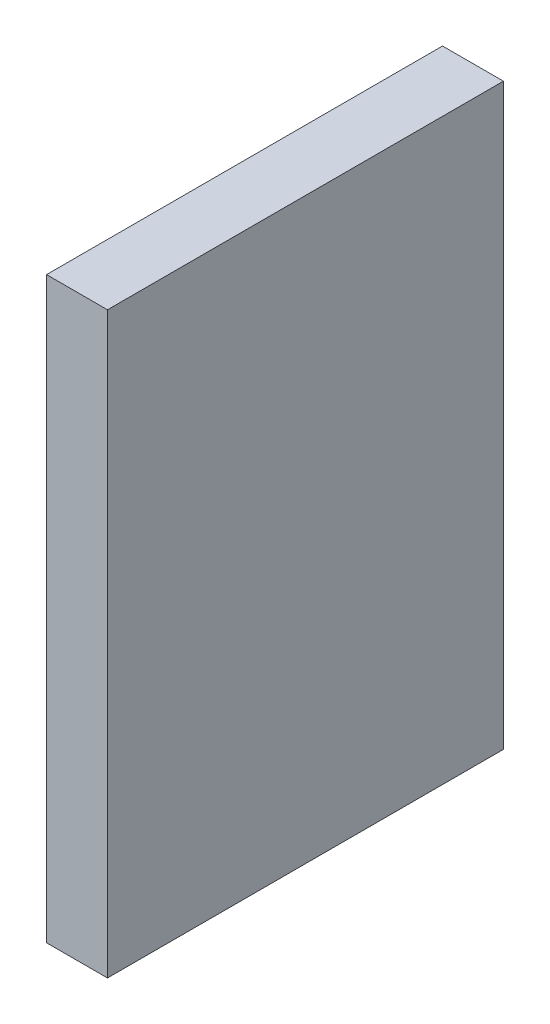
from build123d import *

# Parameters (mm, degrees)
BOSS_EXTRUDE1_DEPTH = 13


with BuildPart() as part:
    # Sketch1 → Boss-Extrude1 (new body)
    with BuildSketch(Plane(origin=(0, 0, 0), x_dir=(1, 0, 0), z_dir=(0, 0, -1))):
        Polygon((0, -9.5), (2, -9.5), (2, 0), (2, 9.5), (0, 9.5), (0, 0), align=None)
    extrude(amount=BOSS_EXTRUDE1_DEPTH)


solid = part.part
